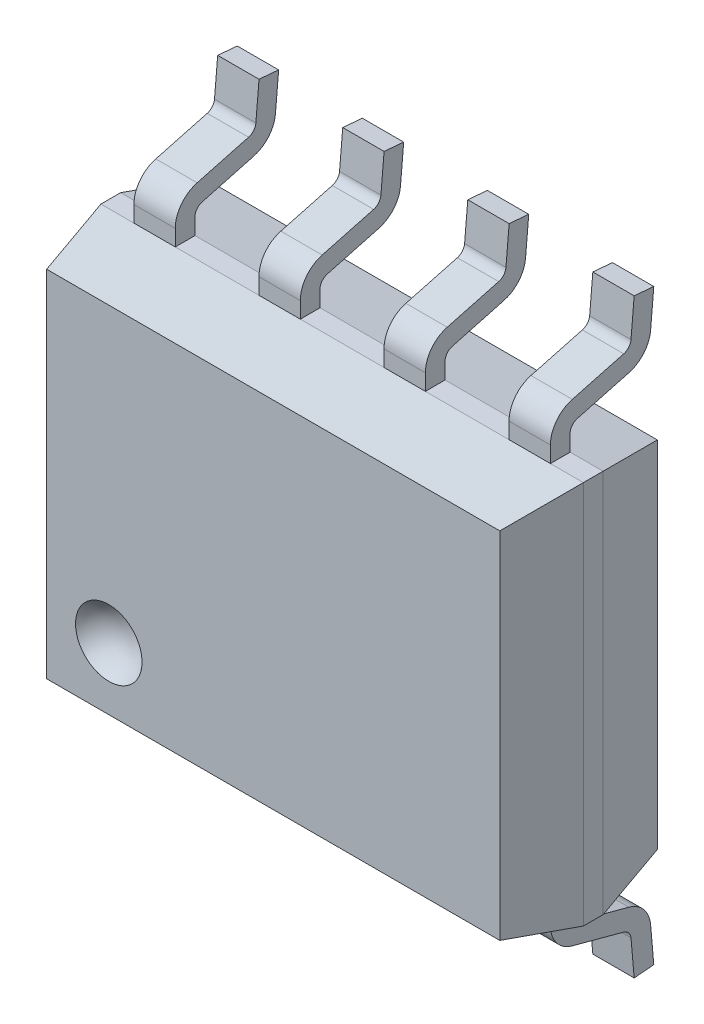
from build123d import *
from OCP.BRepFilletAPI import BRepFilletAPI_MakeChamfer
from build123d.topology import SkipClean

# Parameters (mm, degrees)
BODYWXH_W          = 1.6
BODYWXH_H          = 3.9
BOSS_BODY_DEPTH    = 2.45
CHAMFER1_SIZE      = 0.7
CHAMFER1_SIZE2     = 0.148789593
PINS_DEPTH         = 0.42
PATTERNLEADS_COUNT = 4
PATTERNLEADS_PITCH = 1.27


with BuildPart() as part:
    # BodyWxH → Boss-Body (new, symmetric)
    with BuildSketch(Plane(origin=(0, 0, 0), x_dir=(0, 0, -1), z_dir=(1, 0, 0))):
        with Locations((-0.95, 0)):
            Rectangle(BODYWXH_W, BODYWXH_H)
    extrude(amount=BOSS_BODY_DEPTH, both=True)

    # Chamfer1: one chamfer whose edges measure the first distance from different faces: ONE call of the kernel's chamfer builder (chamfer() names one face for all edges)
    chamfer1_edges_1 = [part.edges().sort_by_distance(p)[0] for p in [
        (0, -1.95, 0.15),
        (0, -1.95, 1.75),
    ]]
    chamfer1_side_1 = [part.faces().sort_by_distance(p)[0] for p in [
        (0, -1.95, 0.95),
    ]]
    chamfer1_edges_2 = [part.edges().sort_by_distance(p)[0] for p in [
        (2.45, 0, 0.15),
        (2.45, 0, 1.75),
    ]]
    chamfer1_side_2 = [part.faces().sort_by_distance(p)[0] for p in [
        (2.45, 0, 0.95),
    ]]
    chamfer1_edges_3 = [part.edges().sort_by_distance(p)[0] for p in [
        (0, 1.95, 0.15),
        (0, 1.95, 1.75),
    ]]
    chamfer1_side_3 = [part.faces().sort_by_distance(p)[0] for p in [
        (0, 1.95, 0.95),
    ]]
    chamfer1_edges_4 = [part.edges().sort_by_distance(p)[0] for p in [
        (-2.45, 0, 0.15),
        (-2.45, 0, 1.75),
    ]]
    chamfer1_side_4 = [part.faces().sort_by_distance(p)[0] for p in [
        (-2.45, 0, 0.95),
    ]]
    chamfer1 = BRepFilletAPI_MakeChamfer(part.part.solid().wrapped)
    for e in chamfer1_edges_1:
        chamfer1.Add(CHAMFER1_SIZE, CHAMFER1_SIZE2, e.wrapped, chamfer1_side_1[0].wrapped)  # the first distance lies on this face
    for e in chamfer1_edges_2:
        chamfer1.Add(CHAMFER1_SIZE, CHAMFER1_SIZE2, e.wrapped, chamfer1_side_2[0].wrapped)  # the first distance lies on this face
    for e in chamfer1_edges_3:
        chamfer1.Add(CHAMFER1_SIZE, CHAMFER1_SIZE2, e.wrapped, chamfer1_side_3[0].wrapped)  # the first distance lies on this face
    for e in chamfer1_edges_4:
        chamfer1.Add(CHAMFER1_SIZE, CHAMFER1_SIZE2, e.wrapped, chamfer1_side_4[0].wrapped)  # the first distance lies on this face
    add(Compound.cast(chamfer1.Shape()), mode=Mode.REPLACE)

    # LeadCross → Pins (add)
    with BuildSketch(Plane(origin=(-2.115, 0, 0), x_dir=(0, 0, -1), z_dir=(1, 0, 0))):
        with BuildLine():
            Line((0, -2.982568851), (-0.19923894, -3))
            Line((-0.19923894, -3), (-0.231516817, -2.631062174))
            ThreePointArc((-0.231516817, -2.631062174), (-0.254531842, -2.575498987), (-0.305254382, -2.543185165))
            Line((-0.305254382, -2.543185165), (-0.827645714, -2.40321083))
            ThreePointArc((-0.827645714, -2.40321083), (-0.988006002, -2.296061511), (-1.05, -2.113433082))
            Line((-1.05, -2.113433082), (-1.05, 2.113433082))
            ThreePointArc((-1.05, 2.113433082), (-0.988006002, 2.296061511), (-0.827645714, 2.40321083))
            Line((-0.827645714, 2.40321083), (-0.305254382, 2.543185165))
            ThreePointArc((-0.305254382, 2.543185165), (-0.254531842, 2.575498987), (-0.231516817, 2.631062174))
            Line((-0.231516817, 2.631062174), (-0.19923894, 3))
            Line((-0.19923894, 3), (0, 2.982568851))
            Line((0, 2.982568851), (-0.032277877, 2.613631025))
            ThreePointArc((-0.032277877, 2.613631025), (-0.101322954, 2.446941465), (-0.253490573, 2.35))
            Line((-0.253490573, 2.35), (-0.775881905, 2.210025665))
            ThreePointArc((-0.775881905, 2.210025665), (-0.829335334, 2.174309225), (-0.85, 2.113433082))
            Line((-0.85, 2.113433082), (-0.85, -2.113433082))
            ThreePointArc((-0.85, -2.113433082), (-0.829335334, -2.174309225), (-0.775881905, -2.210025665))
            Line((-0.775881905, -2.210025665), (-0.253490573, -2.35))
            ThreePointArc((-0.253490573, -2.35), (-0.101322954, -2.446941465), (-0.032277877, -2.613631025))
            Line((-0.032277877, -2.613631025), (0, -2.982568851))
        make_face()
    pins = extrude(amount=PINS_DEPTH)

    # PatternLeads: Pins ×4
    with Locations(*[(i * PATTERNLEADS_PITCH, 0, 0) for i in range(1, PATTERNLEADS_COUNT)]):
        add(pins)

    # Pin1Indent → Cut-Pin1Indent (revolve, cut)
    with SkipClean():  # the faces are left unmerged after this step: merging them gives an invalid solid
        with BuildSketch(Plane(origin=(-1.67, 0, 0), x_dir=(0, 0, -1), z_dir=(1, 0, 0))):
            with BuildLine():
                Line((-1.945, -0.78), (-1.945, -1.56))
                ThreePointArc((-1.945, -1.56), (-1.555, -1.17), (-1.945, -0.78))
            make_face()
        revolve(axis=Axis((-1.67, -0.78, 1.945), (0, -1, 0)), mode=Mode.SUBTRACT)


solid = part.part
